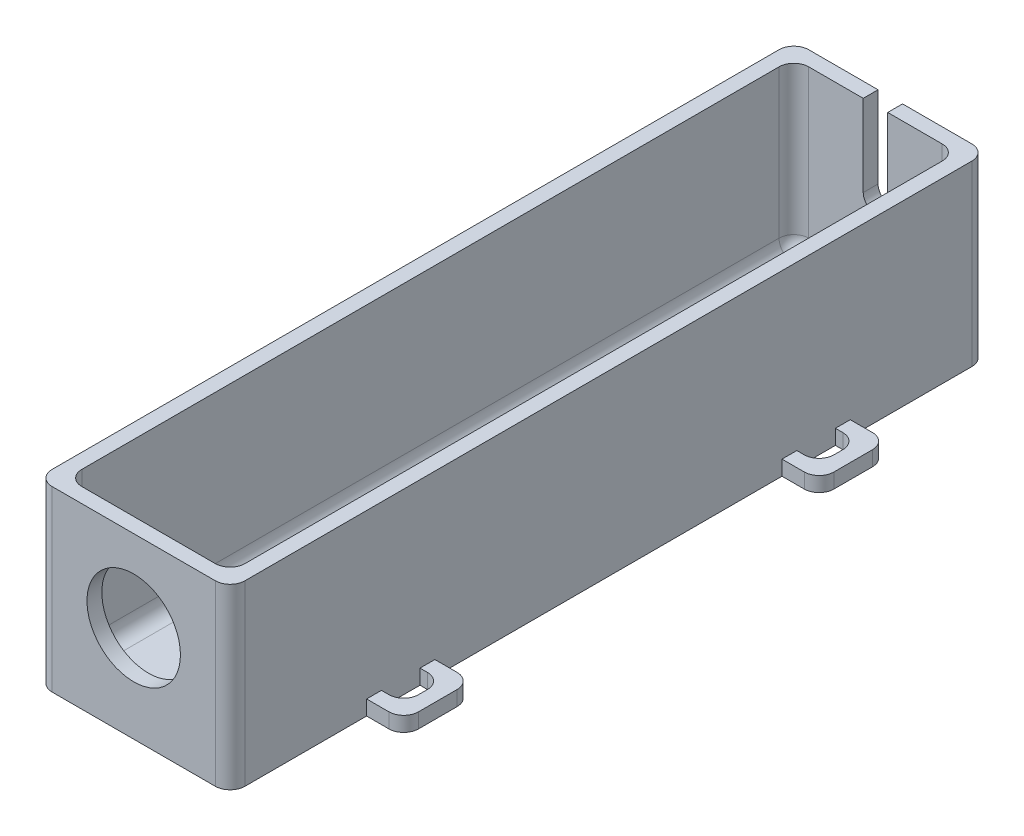
from build123d import *

# Parameters (mm, degrees)
BOSS_EXTRUDE2_DEPTH      = 61.25
BOSS_EXTRUDE2_DEPTH_BACK = 61.25
SKETCH5_W                = 32.5
SKETCH5_H                = 30
SKETCH5_R                = 7.875
BOSS_EXTRUDE3_DEPTH      = 2.5
BOSS_EXTRUDE4_DEPTH      = 2.5
BOSS_EXTRUDE5_DEPTH      = 2.5
FILLET1_R                = 2.5
CUT_EXTRUDE1_DEPTH       = 0.6


with BuildPart() as part:
    # Sketch4 → Boss-Extrude2 (new, two sides: drawn at the far end of the back side and taken through both)
    with BuildSketch(Plane.XY.offset(-BOSS_EXTRUDE2_DEPTH_BACK)):
        Polygon((-16.25, 13.75), (-16.25, -16.25), (16.25, -16.25), (16.25, 13.75), (13.75, 13.75), (13.75, -13.75), (-13.75, -13.75), (-13.75, 13.75), align=None)
    extrude(amount=BOSS_EXTRUDE2_DEPTH + BOSS_EXTRUDE2_DEPTH_BACK)

    # Sketch5 → Boss-Extrude3 (add)
    with BuildSketch(Plane.XY.offset(61.25)):
        with Locations((0, -1.25)):
            Rectangle(SKETCH5_W, SKETCH5_H)
        Circle(SKETCH5_R, mode=Mode.SUBTRACT)
    extrude(amount=BOSS_EXTRUDE3_DEPTH)

    # Sketch7 → Boss-Extrude4 (add)
    with BuildSketch(Plane(origin=(0, 0, -61.25), x_dir=(-1, 0, 0), z_dir=(0, 0, -1))):
        with BuildLine():
            Line((16.25, 13.75), (2.0625, 13.75))
            Line((2.0625, 13.75), (2.0625, 0))
            ThreePointArc((2.0625, 0), (0, -2.0625), (-2.0625, 0))
            Line((-2.0625, 0), (-2.0625, 13.75))
            Line((-2.0625, 13.75), (-16.25, 13.75))
            Line((-16.25, 13.75), (-16.25, -16.25))
            Line((-16.25, -16.25), (16.25, -16.25))
            Line((16.25, -16.25), (16.25, 13.75))
        make_face()
    extrude(amount=BOSS_EXTRUDE4_DEPTH)

    # Sketch8 → Boss-Extrude5 (add)
    with BuildSketch(Plane.XZ.offset(16.25)):
        Polygon((16.25, 31.75), (16.25, 29.25), (22.5, 29.25), (22.5, 40.75), (16.25, 40.75), (16.25, 38.25), (20, 38.25), (20, 31.75), align=None)
        Polygon((22.5, -29.25), (16.25, -29.25), (16.25, -31.75), (20, -31.75), (20, -38.25), (16.25, -38.25), (16.25, -40.75), (22.5, -40.75), align=None)
        Polygon((-22.5, 29.25), (-16.25, 29.25), (-16.25, 31.75), (-20, 31.75), (-20, 38.25), (-16.25, 38.25), (-16.25, 40.75), (-22.5, 40.75), align=None)
        Polygon((-16.25, -31.75), (-16.25, -29.25), (-22.5, -29.25), (-22.5, -40.75), (-16.25, -40.75), (-16.25, -38.25), (-20, -38.25), (-20, -31.75), align=None)
    extrude(amount=-BOSS_EXTRUDE5_DEPTH)

    # Fillet1
    fillet1_edges = [part.edges().sort_by_distance(p)[0] for p in [
        (0, -13.75, -61.25),
        (13.75, -13.75, 0),
        (0, -13.75, 61.25),
        (-13.75, -13.75, 0),
        (-20, -15, -31.75),
        (-22.5, -15, -29.25),
        (-22.5, -15, -40.75),
        (-20, -15, -38.25),
        (-20, -15, 31.75),
        (-20, -15, 38.25),
        (-22.5, -15, 29.25),
        (-22.5, -15, 40.75),
        (20, -15, -38.25),
        (20, -15, -31.75),
        (22.5, -15, -40.75),
        (22.5, -15, -29.25),
        (20, -15, 38.25),
        (20, -15, 31.75),
        (22.5, -15, 40.75),
        (22.5, -15, 29.25),
        (-16.25, -1.25, -63.75),
        (16.25, -1.25, -63.75),
        (16.25, -1.25, 63.75),
        (-16.25, -1.25, 63.75),
        (13.75, 0, 61.25),
        (-13.75, 0, 61.25),
        (-13.75, 0, -61.25),
        (13.75, 0, -61.25),
    ]]
    fillet(fillet1_edges, radius=FILLET1_R)

    # Sketch9 → Cut-Extrude1 (cut)
    # profile 1 of 5: a face of its own
    with BuildSketch(Plane.XZ.offset(16.25)):
        with BuildLine():
            Line((4.725470337, 33.955391126), (7.162212875, 31.292067308))
            add(Edge.make_bspline(
                [(10.322425465, 36.769769131), (10.321847177, 36.304016646), (10.2354185, 35.604773559), (9.95237349, 34.708296299), (9.70395834, 34.164156976), (9.455151182, 33.735020691), (9.231142188, 33.405023036), (8.972898094, 33.068583156), (8.679429422, 32.723940665), (8.352597546, 32.372955803), (7.849710829, 31.886043285), (7.449305614, 31.525594417), (7.162212875, 31.292067308)],
                knots=[0, 0, 0, 0, 0.212967378, 0.319762938, 0.429088889, 0.485861794, 0.546561069, 0.611431094, 0.679817568, 0.753594203, 0.83076014, 1, 1, 1, 1], degree=3))
            add(Edge.make_bspline(
                [(5.289935982, 41.977163462), (5.6247589, 41.979021232), (6.121395682, 41.929201341), (6.761395961, 41.77523117), (7.218461174, 41.612419549), (7.652833616, 41.393797531), (8.071201674, 41.13533864), (8.472835181, 40.831618202), (8.844639099, 40.479099901), (9.190025054, 40.096680516), (9.493199418, 39.687090675), (9.748163672, 39.254607439), (9.962816313, 38.802287295), (10.124196781, 38.324328527), (10.281130935, 37.649052844), (10.320167308, 37.123573519), (10.322425465, 36.769769131)],
                knots=[0, 0, 0, 0, 0.124481382, 0.184876592, 0.244614026, 0.304595172, 0.365487536, 0.427421142, 0.491610276, 0.555859988, 0.618977684, 0.680879876, 0.742423599, 0.804953025, 0.868226542, 1, 1, 1, 1], degree=3))
            add(Edge.make_bspline(
                [(-1.674457047, 36.97647486), (-1.266288252, 37.46289042), (-0.668815734, 38.155367774), (0.12166823, 39.01586959), (0.653456769, 39.56056135), (1.147309349, 40.034398654), (1.598475372, 40.443171754), (2.016120083, 40.777929427), (2.511620801, 41.129963204), (3.112283307, 41.469119389), (4.061378062, 41.848683689), (4.801946474, 41.982684045), (5.289935982, 41.977163462)],
                knots=[0, 0, 0, 0, 0.215220803, 0.309930956, 0.395995516, 0.473179401, 0.541878553, 0.602267112, 0.654474913, 0.747780859, 0.835263266, 1, 1, 1, 1], degree=3))
            add(Edge.make_bspline(
                [(-5.097026909, 34.344951923), (-4.866546834, 34.345741818), (-4.514921474, 34.414476692), (-4.071129742, 34.616244674), (-3.788864721, 34.792322458), (-3.553596343, 34.976247464), (-3.352809974, 35.156470617), (-3.126336111, 35.370085531), (-2.880346634, 35.62251077), (-2.610125541, 35.908854149), (-2.198850308, 36.358313027), (-1.888446737, 36.721914325), (-1.674457047, 36.97647486)],
                knots=[0, 0, 0, 0, 0.155073519, 0.23832497, 0.327891213, 0.378865245, 0.439680162, 0.509886101, 0.588920512, 0.677472341, 0.77557176, 1, 1, 1, 1], degree=3))
            add(Edge.make_bspline(
                [(-6.977254022, 36.610764724), (-6.9804192, 36.311036225), (-6.9097138, 35.870115736), (-6.672261131, 35.333633332), (-6.420200468, 34.994280182), (-6.132342953, 34.706703401), (-5.704963885, 34.432555417), (-5.340021841, 34.339563747), (-5.097026909, 34.344951923)],
                knots=[0, 0, 0, 0, 0.275349454, 0.405273915, 0.536298846, 0.662239886, 0.777966715, 1, 1, 1, 1], degree=3))
            add(Edge.make_bspline(
                [(-4.43318351, 39.862404848), (-4.822838224, 39.649065673), (-5.362449475, 39.302166482), (-5.980811181, 38.764297719), (-6.342196696, 38.361431785), (-6.625600729, 37.945222364), (-6.89492487, 37.376144901), (-6.977881894, 36.915187015), (-6.977254022, 36.610764724)],
                knots=[0, 0, 0, 0, 0.307611547, 0.442138888, 0.566229194, 0.681222208, 0.789558005, 1, 1, 1, 1], degree=3))
            Line((-4.43318351, 39.862404848), (-6.313410623, 42.994791667))
            add(Edge.make_bspline(
                [(-10.53895274, 36.741943359), (-10.538711984, 37.078011973), (-10.509273119, 37.575620679), (-10.402674974, 38.221605547), (-10.289977236, 38.68233067), (-10.148313687, 39.126749542), (-9.972065264, 39.554447), (-9.764607877, 39.964970689), (-9.525835681, 40.360963915), (-9.248745546, 40.739696967), (-8.939100338, 41.106262683), (-8.590186233, 41.456078189), (-8.208813489, 41.796334996), (-7.785186988, 42.114936562), (-7.167203503, 42.542132158), (-6.660883935, 42.816088652), (-6.313410623, 42.994791667)],
                knots=[0, 0, 0, 0, 0.125884922, 0.186264724, 0.245008842, 0.303397551, 0.360818454, 0.41808471, 0.475539922, 0.53381461, 0.593678161, 0.655095496, 0.718734729, 0.784946351, 0.853503068, 1, 1, 1, 1], degree=3))
            add(Edge.make_bspline(
                [(-4.89032118, 30.783253205), (-5.283931554, 30.776893756), (-5.863606259, 30.834652581), (-6.609995429, 31.001151293), (-7.130282311, 31.188645733), (-7.626389287, 31.419467695), (-8.098490988, 31.700686248), (-8.535578306, 32.044525543), (-8.949385276, 32.426443882), (-9.320997077, 32.855415429), (-9.647966287, 33.316974354), (-9.926192388, 33.810258884), (-10.146600209, 34.337111044), (-10.323378719, 34.894298929), (-10.495287775, 35.694188697), (-10.540471078, 36.318963876), (-10.53895274, 36.741943359)],
                knots=[0, 0, 0, 0, 0.12791037, 0.189023009, 0.24851227, 0.307568237, 0.366977671, 0.426948318, 0.488299546, 0.550066462, 0.611349399, 0.672190404, 0.734047645, 0.796944651, 0.862267043, 1, 1, 1, 1], degree=3))
            add(Edge.make_bspline(
                [(-0.338820028, 32.834410056), (-0.696676542, 32.490866738), (-1.243271504, 32.027863794), (-2.008037017, 31.520452716), (-2.556550484, 31.240895091), (-3.111369066, 31.036599708), (-3.881109569, 30.833524898), (-4.484236274, 30.783276585), (-4.89032118, 30.783253205)],
                knots=[0, 0, 0, 0, 0.289911013, 0.41749792, 0.53559687, 0.648803392, 0.762440837, 1, 1, 1, 1], degree=3))
            add(Edge.make_bspline(
                [(1.950843434, 35.390405899), (1.675719557, 35.074461243), (1.289213635, 34.621444757), (0.793002973, 34.059854863), (0.487208245, 33.712581666), (0.22245314, 33.419461391), (-0.047104232, 33.131137199), (-0.228747277, 32.941690489), (-0.338820028, 32.834410056)],
                knots=[0, 0, 0, 0, 0.366184141, 0.520457298, 0.655012135, 0.770624226, 0.865677185, 1, 1, 1, 1], degree=3))
            add(Edge.make_bspline(
                [(4.510814387, 38.085530599), (4.375315195, 37.983898025), (4.162376341, 37.78663162), (3.85471224, 37.482848937), (3.554609973, 37.174587213), (3.214435415, 36.809752957), (2.673450161, 36.209760856), (2.247881525, 35.730433178), (1.950843434, 35.390405899)],
                knots=[0, 0, 0, 0, 0.136347814, 0.233802698, 0.348639747, 0.483184708, 0.635970771, 1, 1, 1, 1], degree=3))
            add(Edge.make_bspline(
                [(5.460865719, 38.415464744), (5.294280054, 38.417907983), (4.954375617, 38.354583534), (4.651526476, 38.189152867), (4.510814387, 38.085530599)],
                knots=[0, 0, 0, 0, 0.487115475, 1, 1, 1, 1], degree=3))
            add(Edge.make_bspline(
                [(6.760726747, 36.809520232), (6.761075687, 37.026293098), (6.722381736, 37.349383069), (6.54159859, 37.728229674), (6.370033405, 37.969340189), (6.16316828, 38.160066197), (5.879160719, 38.360632295), (5.624153679, 38.413573609), (5.460865719, 38.415464744)],
                knots=[0, 0, 0, 0, 0.285992887, 0.416634394, 0.547379946, 0.671582838, 0.784400739, 1, 1, 1, 1], degree=3))
            add(Edge.make_bspline(
                [(4.725470337, 33.955391126), (5.038589073, 34.168199742), (5.469133789, 34.503971278), (5.963613051, 34.997014961), (6.250132815, 35.355201901), (6.480287865, 35.712456685), (6.689489139, 36.187362611), (6.7617665, 36.562792063), (6.760726747, 36.809520232)],
                knots=[0, 0, 0, 0, 0.311847677, 0.448466329, 0.574274609, 0.689053877, 0.79755775, 1, 1, 1, 1], degree=3))
        make_face()
    # profile 2 of 5: a face of its own
    with BuildSketch(Plane.XZ.offset(16.25)):
        with BuildLine():
            Line((9.813611362, 23.071539463), (9.813611362, 27.221554487))
            Line((9.813611362, 27.221554487), (-10.030138638, 27.221554487))
            Line((-10.030138638, 27.221554487), (-10.030138638, 23.659855769))
            Line((-10.030138638, 23.659855769), (-1.380298894, 23.659855769))
            Line((-1.380298894, 23.659855769), (-1.380298894, 22.451422276))
            Line((-1.380298894, 22.451422276), (-10.030138638, 18.078801082))
            Line((-10.030138638, 18.078801082), (-10.030138638, 14.119591346))
            Line((-10.030138638, 14.119591346), (-0.974837656, 18.698918269))
            add(Edge.make_bspline(
                [(4.176905132, 15.010016026), (3.870399931, 15.014744686), (3.417835367, 15.033904739), (2.832138717, 15.129904062), (2.421842204, 15.236611045), (2.02719142, 15.359320252), (1.655474325, 15.522473527), (1.301283215, 15.70661233), (0.969628494, 15.9253074), (0.653144072, 16.165315051), (0.363952911, 16.444438016), (0.086522786, 16.744597219), (-0.161809603, 17.08265105), (-0.39767413, 17.443753842), (-0.689190821, 17.97591974), (-0.870427032, 18.402484846), (-0.974837656, 18.698918269)],
                knots=[0, 0, 0, 0, 0.134789088, 0.19853605, 0.260385651, 0.320961578, 0.37990385, 0.438502936, 0.496154344, 0.554265483, 0.612748761, 0.672513443, 0.733646402, 0.796789619, 0.861935699, 1, 1, 1, 1], degree=3))
            add(Edge.make_bspline(
                [(9.813611362, 23.071539463), (9.816518817, 22.543926414), (9.79762312, 21.782756767), (9.740148633, 20.810025883), (9.676916913, 20.170793699), (9.595039264, 19.593730614), (9.495729604, 19.077613766), (9.383531446, 18.622143606), (9.246016479, 18.221168643), (9.087652486, 17.860306903), (8.908905158, 17.5248749), (8.703020152, 17.208959913), (8.478339839, 16.906763385), (8.226816974, 16.623679374), (7.950489851, 16.360492215), (7.65135023, 16.113817854), (7.33119692, 15.883329527), (6.990476822, 15.678222211), (6.634028012, 15.496503626), (6.260886807, 15.347218245), (5.873191142, 15.222864782), (5.470468002, 15.127313686), (4.904952785, 15.038438532), (4.470928496, 15.004304636), (4.176905132, 15.010016026)],
                knots=[0, 0, 0, 0, 0.140162165, 0.202242855, 0.258850874, 0.310778299, 0.35703697, 0.398448212, 0.43529869, 0.469506816, 0.503054622, 0.536158017, 0.569602223, 0.603018625, 0.636632862, 0.670889864, 0.705962026, 0.741342038, 0.776451285, 0.812145172, 0.847994966, 0.884541502, 0.921987497, 1, 1, 1, 1], degree=3))
        make_face()
        with BuildLine():
            Line((2.181399824, 22.272542318), (2.181399824, 23.659855769))
            Line((2.181399824, 23.659855769), (6.251912644, 23.659855769))
            Line((6.251912644, 23.659855769), (6.251912644, 22.447447165))
            add(Edge.make_bspline(
                [(4.224606454, 18.571714744), (4.430856142, 18.569336033), (4.737821668, 18.617899001), (5.109040757, 18.787942636), (5.360873321, 18.959576494), (5.581882576, 19.1759148), (5.775115754, 19.423678797), (5.931475521, 19.706617215), (6.031615931, 19.970456686), (6.093168766, 20.212165473), (6.136863188, 20.429590711), (6.170742718, 20.68205454), (6.203537828, 20.96814839), (6.226123151, 21.289101548), (6.248405378, 21.78598117), (6.249131161, 22.175840499), (6.251912644, 22.447447165)],
                knots=[0, 0, 0, 0, 0.125251327, 0.185397333, 0.246785132, 0.309395271, 0.372500033, 0.436990651, 0.505000956, 0.543261349, 0.588402702, 0.639620714, 0.697923877, 0.763292366, 0.834993066, 1, 1, 1, 1], degree=3))
            add(Edge.make_bspline(
                [(2.181399824, 22.272542318), (2.186148264, 21.948012032), (2.187739225, 21.480060162), (2.244800082, 20.886900453), (2.296470587, 20.503743321), (2.356092402, 20.159674216), (2.441597681, 19.857834248), (2.533050755, 19.593359109), (2.647248209, 19.370046032), (2.77483177, 19.17847477), (2.926164536, 19.017895772), (3.091942318, 18.876443148), (3.28259563, 18.765443341), (3.49032719, 18.675931058), (3.805527125, 18.598524949), (4.053049262, 18.566470029), (4.224606454, 18.571714744)],
                knots=[0, 0, 0, 0, 0.202121753, 0.290735729, 0.370617406, 0.442747669, 0.507763702, 0.565672102, 0.616562461, 0.66344735, 0.708377216, 0.753458159, 0.798569257, 0.845126707, 0.893727678, 1, 1, 1, 1], degree=3))
        make_face(mode=Mode.SUBTRACT)
    # profile 3 of 5: a face of its own
    with BuildSketch(Plane.XZ.offset(16.25)):
        Polygon((9.813611362, 1.780849359), (9.813611362, 5.084165915), (-10.030138638, 13.101963141), (-10.030138638, 9.301757813), (-5.959625817, 7.759415064), (-5.959625817, -0.886449569), (-10.030138638, -2.428792318), (-10.030138638, -6.232972756), align=None)
        Polygon((-2.397927099, 6.407877604), (4.490938836, 3.434495192), (-2.397927099, 0.46111278), align=None, mode=Mode.SUBTRACT)
    # profile 4 of 5: a face of its own
    with BuildSketch(Plane.XZ.offset(16.25)):
        with BuildLine():
            Line((9.813611362, -12.720352564), (9.813611362, -9.158653846))
            Line((9.813611362, -9.158653846), (-2.024266743, -9.158653846))
            add(Edge.make_bspline(
                [(-10.53895274, -15.657958984), (-10.540230498, -15.320382093), (-10.506894898, -14.822178036), (-10.406283251, -14.173273862), (-10.29871719, -13.710865668), (-10.159263545, -13.264423242), (-9.98915596, -12.834527814), (-9.784343663, -12.423937291), (-9.554035577, -12.031209826), (-9.301587798, -11.658342734), (-9.026391913, -11.314064488), (-8.740245724, -10.993552886), (-8.437233364, -10.702573213), (-8.11848702, -10.439247212), (-7.783638746, -10.203836356), (-7.432625341, -9.996764072), (-7.059144485, -9.812801969), (-6.644206827, -9.655349402), (-6.173054706, -9.522610548), (-5.638302834, -9.406647424), (-5.038746133, -9.320468028), (-4.376362717, -9.242348037), (-3.365049408, -9.173499464), (-2.572916385, -9.163579882), (-2.024266743, -9.158653846)],
                knots=[0, 0, 0, 0, 0.082305772, 0.121576344, 0.160073088, 0.198001139, 0.235574948, 0.272725113, 0.309811947, 0.346569126, 0.382460565, 0.417249298, 0.451311178, 0.484833549, 0.518012895, 0.55105182, 0.584155508, 0.619452567, 0.659145209, 0.703460499, 0.752830906, 0.806837116, 0.866136951, 1, 1, 1, 1], degree=3))
            add(Edge.make_bspline(
                [(-2.024266743, -22.133413462), (-2.485402431, -22.134007027), (-3.148387585, -22.128012826), (-3.993570199, -22.08838684), (-4.540958923, -22.053276917), (-5.031714087, -22.011142911), (-5.465584153, -21.956621456), (-5.842336819, -21.88992477), (-6.271173592, -21.789965253), (-6.764978032, -21.617694773), (-7.333567432, -21.339880769), (-7.89024815, -20.987235739), (-8.428916273, -20.570429569), (-8.929255289, -20.099784594), (-9.368726634, -19.585888801), (-9.738954644, -19.037330132), (-10.035989241, -18.449640485), (-10.265199092, -17.818617878), (-10.476924646, -16.888523031), (-10.544099812, -16.157890706), (-10.53895274, -15.657958984)],
                knots=[0, 0, 0, 0, 0.112565726, 0.161777311, 0.206503762, 0.246442895, 0.281985009, 0.313197744, 0.339790858, 0.389396209, 0.440456267, 0.493936678, 0.549958926, 0.606468236, 0.661297783, 0.714669534, 0.767607383, 0.821626844, 0.878109308, 1, 1, 1, 1], degree=3))
            Line((-2.024266743, -22.133413462), (9.813611362, -22.133413462))
            Line((9.813611362, -22.133413462), (9.813611362, -18.571714744))
            Line((9.813611362, -18.571714744), (-2.624508379, -18.571714744))
            add(Edge.make_bspline(
                [(-6.977254022, -15.578456781), (-6.980097637, -15.891837144), (-6.925167087, -16.351794013), (-6.731537, -16.924408593), (-6.526233753, -17.300698579), (-6.283569239, -17.634836243), (-6.000306911, -17.912051472), (-5.690837902, -18.140359068), (-5.399471006, -18.283871998), (-5.133843065, -18.367124726), (-4.8944615, -18.421614864), (-4.61438561, -18.468506514), (-4.294855321, -18.508431624), (-3.933802919, -18.533083957), (-3.373815793, -18.569966991), (-2.931819186, -18.569102884), (-2.624508379, -18.571714744)],
                knots=[0, 0, 0, 0, 0.153651293, 0.225205693, 0.295309819, 0.363189792, 0.427095472, 0.488998561, 0.551225173, 0.585357667, 0.625415875, 0.671591837, 0.724655611, 0.783347837, 0.849131002, 1, 1, 1, 1], degree=3))
            add(Edge.make_bspline(
                [(-3.09754649, -12.720352564), (-3.356199835, -12.716011483), (-3.727213674, -12.732562781), (-4.201830933, -12.756839713), (-4.512450578, -12.787685665), (-4.792860432, -12.833378047), (-5.044864281, -12.87760317), (-5.263949674, -12.937463496), (-5.513326313, -13.027422515), (-5.793514102, -13.166020172), (-6.085534349, -13.392481363), (-6.352037299, -13.653796461), (-6.573894391, -13.967004629), (-6.753239717, -14.318996048), (-6.935854527, -14.851745797), (-6.971467286, -15.285626425), (-6.977254022, -15.578456781)],
                knots=[0, 0, 0, 0, 0.139489766, 0.200369998, 0.256432726, 0.307803522, 0.353658517, 0.394419906, 0.430155706, 0.496666273, 0.562017618, 0.628754548, 0.697409641, 0.768079195, 0.841338126, 1, 1, 1, 1], degree=3))
            Line((-3.09754649, -12.720352564), (9.813611362, -12.720352564))
        make_face()
    # profile 5 of 5: a face of its own
    with BuildSketch(Plane.XZ.offset(16.25)):
        Polygon((9.813611362, -28.86327499), (9.813611362, -25.059094551), (-10.030138638, -32.24211864), (-10.030138638, -35.672638722), (9.813611362, -42.867588141), (9.813611362, -39.075333033), (-4.282129323, -33.963341346), align=None)
    extrude(amount=-CUT_EXTRUDE1_DEPTH, mode=Mode.SUBTRACT)


solid = part.part
